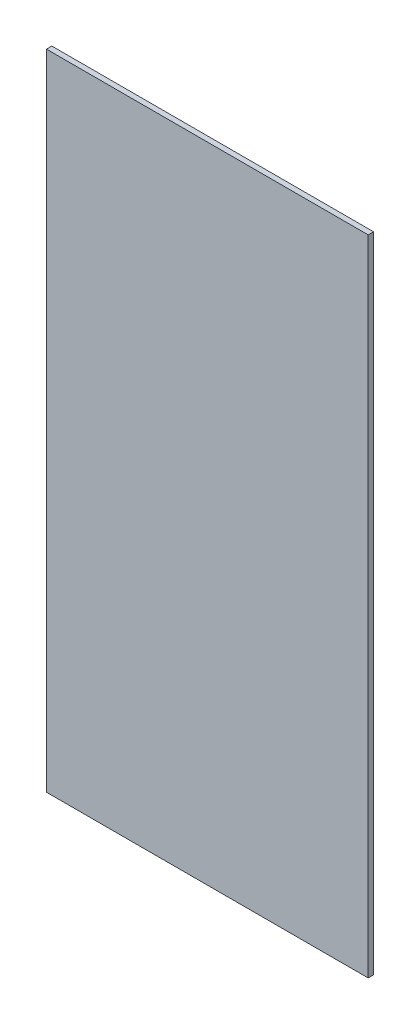
from build123d import *

# Parameters (mm, degrees)
SKETCH1_W           = 152.4
SKETCH1_H           = 304.8
BOSS_EXTRUDE1_DEPTH = 1.27


with BuildPart() as part:
    # Sketch1 → Boss-Extrude1 (new body, symmetric)
    with BuildSketch(Plane.XY):
        Rectangle(SKETCH1_W, SKETCH1_H)
    extrude(amount=BOSS_EXTRUDE1_DEPTH, both=True)


solid = part.part
